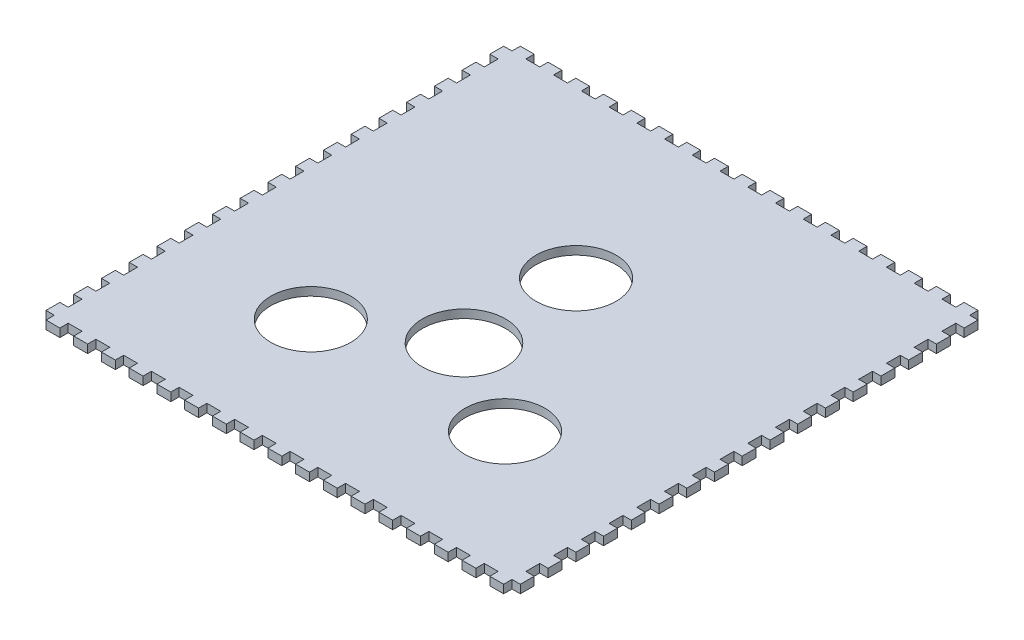
from build123d import *

# Parameters (mm, degrees)
SKETCH_1_R      = 14.43375673
SKETCH_1_R_2    = 15
EXTRUDE_2_DEPTH = 3


with BuildPart() as part:
    # Эскиз1 → Бобышка-Вытянуть2 (new body)
    with BuildSketch(Plane(origin=(0, 0, 0), x_dir=(1, 0, 0), z_dir=(0, 1, 0))):
        Polygon((0, 165), (0, 168), (5, 168), (5, 165), (10, 165), (10, 168), (15, 168), (15, 165), (20, 165), (20, 168), (25, 168), (25, 165), (30, 165), (30, 168), (35, 168), (35, 165), (40, 165), (40, 168), (45, 168), (45, 165), (50, 165), (50, 168), (55, 168), (55, 165), (60, 165), (60, 168), (65, 168), (65, 165), (70, 165), (70, 168), (75, 168), (75, 165), (80, 165), (80, 168), (85, 168), (85, 165), (90, 165), (90, 168), (95, 168), (95, 165), (100, 165), (100, 168), (105, 168), (105, 165), (110, 165), (110, 168), (115, 168), (115, 165), (120, 165), (120, 168), (125, 168), (125, 165), (130, 165), (130, 168), (135, 168), (135, 165), (140, 165), (140, 168), (145, 168), (145, 165), (150, 165), (150, 168), (155, 168), (155, 165), (160, 165), (160, 168), (165, 168), (165, 165), (168, 165), (168, 160), (165, 160), (165, 155), (168, 155), (168, 150), (165, 150), (165, 145), (168, 145), (168, 140), (165, 140), (165, 135), (168, 135), (168, 130), (165, 130), (165, 125), (168, 125), (168, 120), (165, 120), (165, 115), (168, 115), (168, 110), (165, 110), (165, 105), (168, 105), (168, 100), (165, 100), (165, 95), (168, 95), (168, 90), (165, 90), (165, 85), (168, 85), (168, 80), (165, 80), (165, 75), (168, 75), (168, 70), (165, 70), (165, 65), (168, 65), (168, 60), (165, 60), (165, 55), (168, 55), (168, 50), (165, 50), (165, 45), (168, 45), (168, 40), (165, 40), (165, 35), (168, 35), (168, 30), (165, 30), (165, 25), (168, 25), (168, 20), (165, 20), (165, 15), (168, 15), (168, 10), (165, 10), (165, 5), (168, 5), (168, 0), (165, 0), (165, -3), (160, -3), (160, 0), (155, 0), (155, -3), (150, -3), (150, 0), (145, 0), (145, -3), (140, -3), (140, 0), (135, 0), (135, -3), (130, -3), (130, 0), (125, 0), (125, -3), (120, -3), (120, 0), (115, 0), (115, -3), (110, -3), (110, 0), (105, 0), (105, -3), (100, -3), (100, 0), (95, 0), (95, -3), (90, -3), (90, 0), (85, 0), (85, -3), (80, -3), (80, 0), (75, 0), (75, -3), (70, -3), (70, 0), (65, 0), (65, -3), (60, -3), (60, 0), (55, 0), (55, -3), (50, -3), (50, 0), (45, 0), (45, -3), (40, -3), (40, 0), (35, 0), (35, -3), (30, -3), (30, 0), (25, 0), (25, -3), (20, -3), (20, 0), (15, 0), (15, -3), (10, -3), (10, 0), (5, 0), (5, -3), (0, -3), (0, 0), (-3, 0), (-3, 5), (0, 5), (0, 10), (-3, 10), (-3, 15), (0, 15), (0, 20), (-3, 20), (-3, 25), (0, 25), (0, 30), (-3, 30), (-3, 35), (0, 35), (0, 40), (-3, 40), (-3, 45), (0, 45), (0, 50), (-3, 50), (-3, 55), (0, 55), (0, 60), (-3, 60), (-3, 65), (0, 65), (0, 70), (-3, 70), (-3, 75), (0, 75), (0, 80), (-3, 80), (-3, 85), (0, 85), (0, 90), (-3, 90), (-3, 95), (0, 95), (0, 100), (-3, 100), (-3, 105), (0, 105), (0, 110), (-3, 110), (-3, 115), (0, 115), (0, 120), (-3, 120), (-3, 125), (0, 125), (0, 130), (-3, 130), (-3, 135), (0, 135), (0, 140), (-3, 140), (-3, 145), (0, 145), (0, 150), (-3, 150), (-3, 155), (0, 155), (0, 160), (-3, 160), (-3, 165), align=None)
        with Locations((47.5, 44.972232503)):
            Circle(SKETCH_1_R, mode=Mode.SUBTRACT)
        with Locations((117.5, 44.972232503)):
            Circle(SKETCH_1_R, mode=Mode.SUBTRACT)
        with Locations((82.5, 105.594010768)):
            Circle(SKETCH_1_R, mode=Mode.SUBTRACT)
        with Locations((82.5, 65.179491924)):
            Circle(SKETCH_1_R_2, mode=Mode.SUBTRACT)
    extrude(amount=EXTRUDE_2_DEPTH)


solid = part.part
